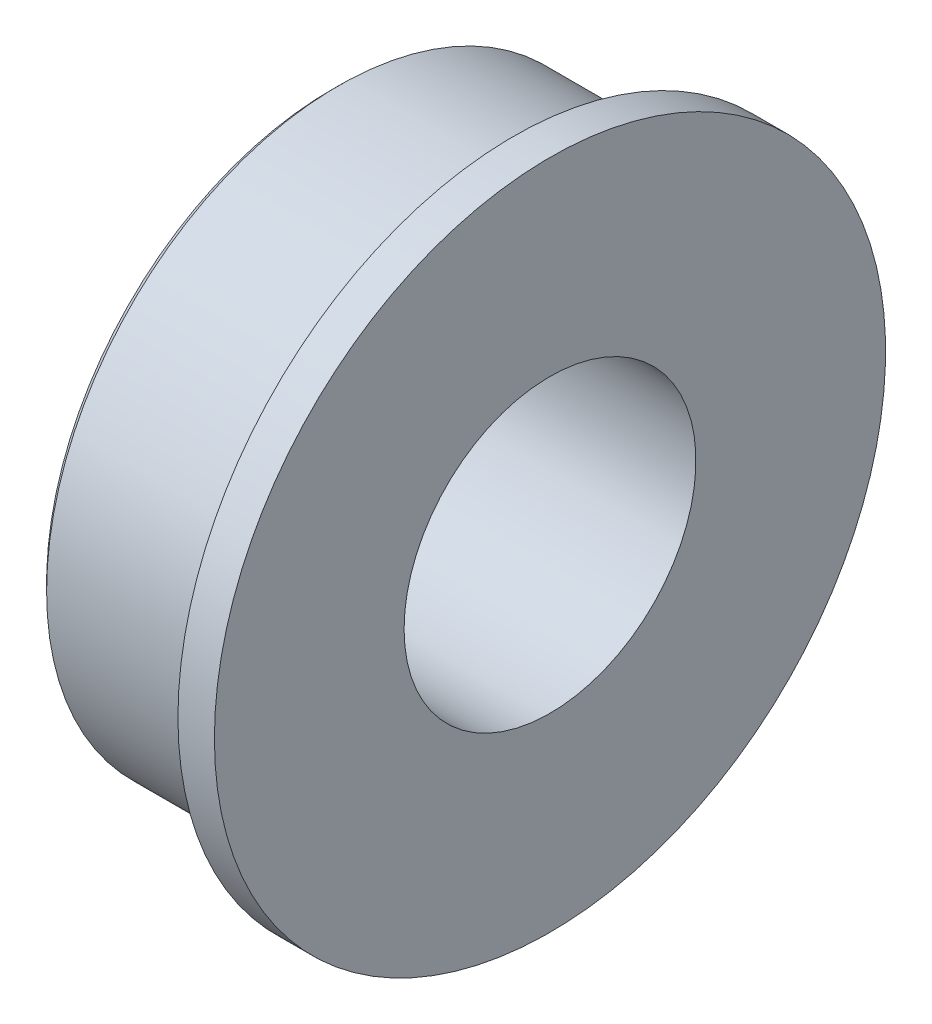
from build123d import *

# Parameters (mm, degrees)
CHAMFER_1_SIZE = 0.1


with BuildPart() as part:
    # 草图1 → 旋转1 (revolve)
    with BuildSketch(Plane.XY):
        Polygon((0, 2), (0, 4), (2.5, 4), (2.5, 4.6), (3, 4.6), (3, 2), align=None)
    revolve(axis=Axis((0, 0, 0), (1, 0, 0)))

    # 倒角1
    chamfer_1_edges = [part.edges().sort_by_distance(p)[0] for p in [
        (0, -4, 0),
    ]]
    chamfer(chamfer_1_edges, length=CHAMFER_1_SIZE)


solid = part.part
